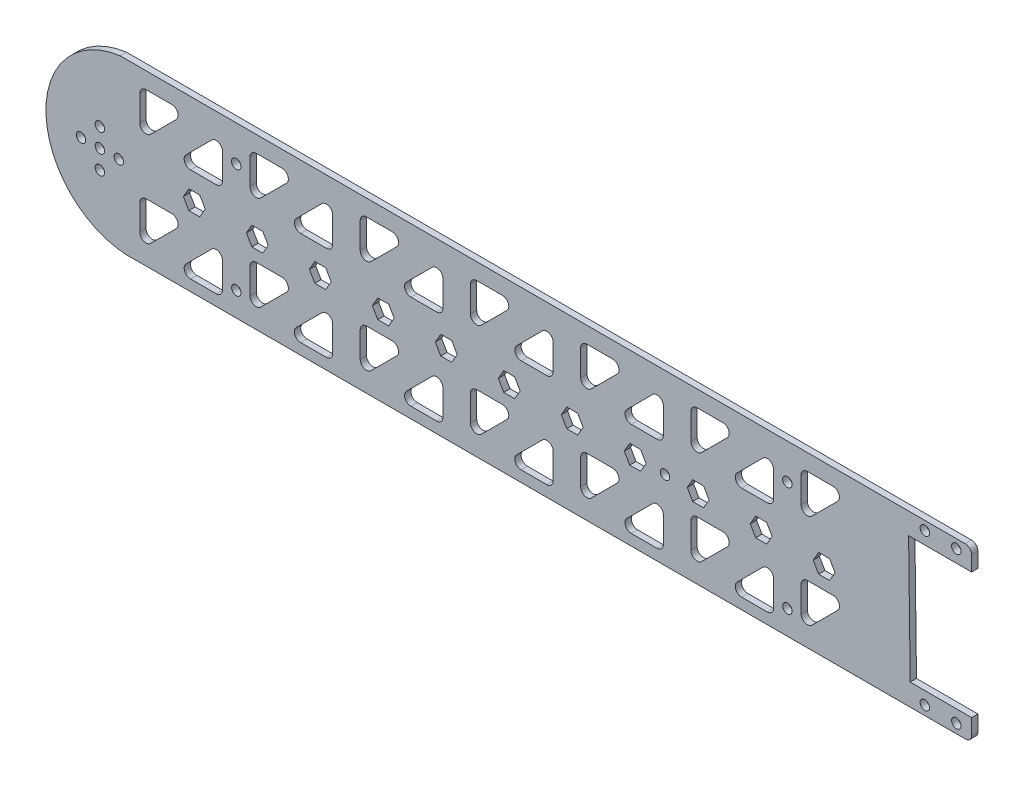
from build123d import *

# Parameters (mm, degrees)
IZIM1_R                     = 1.5
Y_KSEKLIK_EKSTR_ZYON2_DEPTH = 2
IZIM9_R                     = 1.5
KES_EKSTR_ZYON5_DEPTH       = 10
IZIM10_R                    = 1.5
KES_EKSTR_ZYON7_DEPTH       = 10


with BuildPart() as part:
    # Çizim1 → Yükseklik-Ekstrüzyon2 (new body)
    with BuildSketch(Plane.XY):
        with BuildLine():
            ThreePointArc((-123.68208832, 28.6803889), (-147.097650837, -0.85979795), (-118.162671893, -25.019230903))
            Line((-118.162671893, -25.019230903), (122.31562704, -25.019230903))
            Line((122.31562704, -25.019230903), (144.746839173, -25.019230903))
            ThreePointArc((144.746839173, -25.019230903), (146.161052735, -24.433444465), (146.746839173, -23.019230903))
            Line((146.746839173, -23.019230903), (146.746839173, -18.118237576))
            Line((146.746839173, -18.118237576), (127.216282083, -18.118237576))
            Line((127.216282083, -18.118237576), (126.706405407, 21.900803601))
            Line((126.706405407, 21.900803601), (146.706405407, 21.900803601))
            Line((146.706405407, 21.900803601), (146.706405407, 26.6803889))
            ThreePointArc((146.706405407, 26.6803889), (146.120618969, 28.094602463), (144.706405407, 28.6803889))
            Line((144.706405407, 28.6803889), (-123.68208832, 28.6803889))
        make_face()
        with BuildLine():
            Line((-117.432950192, -16.684982837), (-117.432950192, -8.513409962))
            ThreePointArc((-117.432950192, -8.513409962), (-116.847163754, -7.099196399), (-115.432950192, -6.513409962))
            Line((-115.432950192, -6.513409962), (-107.261377316, -6.513409962))
            ThreePointArc((-107.261377316, -6.513409962), (-105.413618251, -7.748043097), (-105.847163754, -9.927623524))
            Line((-105.847163754, -9.927623524), (-114.018736629, -18.099196399))
            ThreePointArc((-114.018736629, -18.099196399), (-116.198317056, -18.532741902), (-117.432950192, -16.684982837))
        make_face(mode=Mode.SUBTRACT)
        with BuildLine():
            Line((-102.756511954, -18.099196399), (-94.584939079, -9.927623524))
            ThreePointArc((-94.584939079, -9.927623524), (-92.405358652, -9.494078021), (-91.170725517, -11.341837086))
            Line((-91.170725517, -11.341837086), (-91.170725517, -19.513409962))
            ThreePointArc((-91.170725517, -19.513409962), (-91.756511954, -20.927623524), (-93.170725517, -21.513409962))
            Line((-93.170725517, -21.513409962), (-101.342298392, -21.513409962))
            ThreePointArc((-101.342298392, -21.513409962), (-103.190057457, -20.278776826), (-102.756511954, -18.099196399))
        make_face(mode=Mode.SUBTRACT)
        with BuildLine():
            Line((-82.432950192, -16.684982837), (-82.432950192, -8.513409962))
            ThreePointArc((-82.432950192, -8.513409962), (-81.847163754, -7.099196399), (-80.432950192, -6.513409962))
            Line((-80.432950192, -6.513409962), (-72.261377316, -6.513409962))
            ThreePointArc((-72.261377316, -6.513409962), (-70.413618251, -7.748043097), (-70.847163754, -9.927623524))
            Line((-70.847163754, -9.927623524), (-79.018736629, -18.099196399))
            ThreePointArc((-79.018736629, -18.099196399), (-81.198317056, -18.532741902), (-82.432950192, -16.684982837))
        make_face(mode=Mode.SUBTRACT)
        with BuildLine():
            Line((-67.756511954, -18.099196399), (-59.584939079, -9.927623524))
            ThreePointArc((-59.584939079, -9.927623524), (-57.405358652, -9.494078021), (-56.170725517, -11.341837086))
            Line((-56.170725517, -11.341837086), (-56.170725517, -19.513409962))
            ThreePointArc((-56.170725517, -19.513409962), (-56.756511954, -20.927623524), (-58.170725517, -21.513409962))
            Line((-58.170725517, -21.513409962), (-66.342298392, -21.513409962))
            ThreePointArc((-66.342298392, -21.513409962), (-68.190057457, -20.278776826), (-67.756511954, -18.099196399))
        make_face(mode=Mode.SUBTRACT)
        with BuildLine():
            Line((-47.432950192, -16.684982837), (-47.432950192, -8.513409962))
            ThreePointArc((-47.432950192, -8.513409962), (-46.847163754, -7.099196399), (-45.432950192, -6.513409962))
            Line((-45.432950192, -6.513409962), (-37.261377316, -6.513409962))
            ThreePointArc((-37.261377316, -6.513409962), (-35.413618251, -7.748043097), (-35.847163754, -9.927623524))
            Line((-35.847163754, -9.927623524), (-44.018736629, -18.099196399))
            ThreePointArc((-44.018736629, -18.099196399), (-46.198317056, -18.532741902), (-47.432950192, -16.684982837))
        make_face(mode=Mode.SUBTRACT)
        with BuildLine():
            Line((-32.756511954, -18.099196399), (-24.584939079, -9.927623524))
            ThreePointArc((-24.584939079, -9.927623524), (-22.405358652, -9.494078021), (-21.170725517, -11.341837086))
            Line((-21.170725517, -11.341837086), (-21.170725517, -19.513409962))
            ThreePointArc((-21.170725517, -19.513409962), (-21.756511954, -20.927623524), (-23.170725517, -21.513409962))
            Line((-23.170725517, -21.513409962), (-31.342298392, -21.513409962))
            ThreePointArc((-31.342298392, -21.513409962), (-33.190057457, -20.278776826), (-32.756511954, -18.099196399))
        make_face(mode=Mode.SUBTRACT)
        with BuildLine():
            Line((-12.432950192, -16.684982837), (-12.432950192, -8.513409962))
            ThreePointArc((-12.432950192, -8.513409962), (-11.847163754, -7.099196399), (-10.432950192, -6.513409962))
            Line((-10.432950192, -6.513409962), (-2.261377316, -6.513409962))
            ThreePointArc((-2.261377316, -6.513409962), (-0.413618251, -7.748043097), (-0.847163754, -9.927623524))
            Line((-0.847163754, -9.927623524), (-9.018736629, -18.099196399))
            ThreePointArc((-9.018736629, -18.099196399), (-11.198317056, -18.532741902), (-12.432950192, -16.684982837))
        make_face(mode=Mode.SUBTRACT)
        Polygon((-96.652716692, 0.01885212), (-98.388672632, -2.978889859), (-101.85277131, -2.974378905), (-103.580914048, 0.027874028), (-101.844958108, 3.025616007), (-98.38085943, 3.021105053), align=None, mode=Mode.SUBTRACT)
        Polygon((-76.652716692, 0.01885212), (-78.388672632, -2.978889859), (-81.85277131, -2.974378905), (-83.580914048, 0.027874028), (-81.844958108, 3.025616007), (-78.38085943, 3.021105053), align=None, mode=Mode.SUBTRACT)
        Polygon((-56.652716692, 0.01885212), (-58.388672632, -2.978889859), (-61.85277131, -2.974378905), (-63.580914048, 0.027874028), (-61.844958108, 3.025616007), (-58.38085943, 3.021105053), align=None, mode=Mode.SUBTRACT)
        Polygon((-36.652716692, 0.01885212), (-38.388672632, -2.978889859), (-41.85277131, -2.974378905), (-43.580914048, 0.027874028), (-41.844958108, 3.025616007), (-38.38085943, 3.021105053), align=None, mode=Mode.SUBTRACT)
        Polygon((-16.652716692, 0.01885212), (-18.388672632, -2.978889859), (-21.85277131, -2.974378905), (-23.580914048, 0.027874028), (-21.844958108, 3.025616007), (-18.38085943, 3.021105053), align=None, mode=Mode.SUBTRACT)
        Polygon((3.347283308, 0.01885212), (1.611327368, -2.978889859), (-1.85277131, -2.974378905), (-3.580914048, 0.027874028), (-1.844958108, 3.025616007), (1.61914057, 3.021105053), align=None, mode=Mode.SUBTRACT)
        with BuildLine():
            Line((2.243488046, -18.099196399), (10.415060921, -9.927623524))
            ThreePointArc((10.415060921, -9.927623524), (12.594641348, -9.494078021), (13.829274483, -11.341837086))
            Line((13.829274483, -11.341837086), (13.829274483, -19.513409962))
            ThreePointArc((13.829274483, -19.513409962), (13.243488046, -20.927623524), (11.829274483, -21.513409962))
            Line((11.829274483, -21.513409962), (3.657701608, -21.513409962))
            ThreePointArc((3.657701608, -21.513409962), (1.809942543, -20.278776826), (2.243488046, -18.099196399))
        make_face(mode=Mode.SUBTRACT)
        with BuildLine():
            Line((22.567049808, -16.684982837), (22.567049808, -8.513409962))
            ThreePointArc((22.567049808, -8.513409962), (23.152836246, -7.099196399), (24.567049808, -6.513409962))
            Line((24.567049808, -6.513409962), (32.738622684, -6.513409962))
            ThreePointArc((32.738622684, -6.513409962), (34.586381749, -7.748043097), (34.152836246, -9.927623524))
            Line((34.152836246, -9.927623524), (25.981263371, -18.099196399))
            ThreePointArc((25.981263371, -18.099196399), (23.801682944, -18.532741902), (22.567049808, -16.684982837))
        make_face(mode=Mode.SUBTRACT)
        with BuildLine():
            Line((37.243488046, -18.099196399), (45.415060921, -9.927623524))
            ThreePointArc((45.415060921, -9.927623524), (47.594641348, -9.494078021), (48.829274483, -11.341837086))
            Line((48.829274483, -11.341837086), (48.829274483, -19.513409962))
            ThreePointArc((48.829274483, -19.513409962), (48.243488046, -20.927623524), (46.829274483, -21.513409962))
            Line((46.829274483, -21.513409962), (38.657701608, -21.513409962))
            ThreePointArc((38.657701608, -21.513409962), (36.809942543, -20.278776826), (37.243488046, -18.099196399))
        make_face(mode=Mode.SUBTRACT)
        with BuildLine():
            Line((57.567049808, -16.684982837), (57.567049808, -8.513409962))
            ThreePointArc((57.567049808, -8.513409962), (58.152836246, -7.099196399), (59.567049808, -6.513409962))
            Line((59.567049808, -6.513409962), (67.738622684, -6.513409962))
            ThreePointArc((67.738622684, -6.513409962), (69.586381749, -7.748043097), (69.152836246, -9.927623524))
            Line((69.152836246, -9.927623524), (60.981263371, -18.099196399))
            ThreePointArc((60.981263371, -18.099196399), (58.801682944, -18.532741902), (57.567049808, -16.684982837))
        make_face(mode=Mode.SUBTRACT)
        with Locations((131.859799091, -22.099196399)):
            Circle(IZIM1_R, mode=Mode.SUBTRACT)
        with Locations((141.859799091, -22.099196399)):
            Circle(IZIM1_R, mode=Mode.SUBTRACT)
        with BuildLine():
            Line((72.243488046, -18.099196399), (80.415060921, -9.927623524))
            ThreePointArc((80.415060921, -9.927623524), (82.594641348, -9.494078021), (83.829274483, -11.341837086))
            Line((83.829274483, -11.341837086), (83.829274483, -19.513409962))
            ThreePointArc((83.829274483, -19.513409962), (83.243488046, -20.927623524), (81.829274483, -21.513409962))
            Line((81.829274483, -21.513409962), (73.657701608, -21.513409962))
            ThreePointArc((73.657701608, -21.513409962), (71.809942543, -20.278776826), (72.243488046, -18.099196399))
        make_face(mode=Mode.SUBTRACT)
        with BuildLine():
            Line((92.567049808, -16.684982837), (92.567049808, -8.513409962))
            ThreePointArc((92.567049808, -8.513409962), (93.152836246, -7.099196399), (94.567049808, -6.513409962))
            Line((94.567049808, -6.513409962), (102.738622684, -6.513409962))
            ThreePointArc((102.738622684, -6.513409962), (104.586381749, -7.748043097), (104.152836246, -9.927623524))
            Line((104.152836246, -9.927623524), (95.981263371, -18.099196399))
            ThreePointArc((95.981263371, -18.099196399), (93.801682944, -18.532741902), (92.567049808, -16.684982837))
        make_face(mode=Mode.SUBTRACT)
        Polygon((23.347283308, 0.01885212), (21.611327368, -2.978889859), (18.14722869, -2.974378905), (16.419085952, 0.027874028), (18.155041892, 3.025616007), (21.61914057, 3.021105053), align=None, mode=Mode.SUBTRACT)
        Polygon((43.347283308, 0.01885212), (41.611327368, -2.978889859), (38.14722869, -2.974378905), (36.419085952, 0.027874028), (38.155041892, 3.025616007), (41.61914057, 3.021105053), align=None, mode=Mode.SUBTRACT)
        Polygon((63.347283308, 0.01885212), (61.611327368, -2.978889859), (58.14722869, -2.974378905), (56.419085952, 0.027874028), (58.155041892, 3.025616007), (61.61914057, 3.021105053), align=None, mode=Mode.SUBTRACT)
        Polygon((83.347283308, 0.01885212), (81.611327368, -2.978889859), (78.14722869, -2.974378905), (76.419085952, 0.027874028), (78.155041892, 3.025616007), (81.61914057, 3.021105053), align=None, mode=Mode.SUBTRACT)
        Polygon((103.347283308, 0.01885212), (101.611327368, -2.978889859), (98.14722869, -2.974378905), (96.419085952, 0.027874028), (98.155041892, 3.025616007), (101.61914057, 3.021105053), align=None, mode=Mode.SUBTRACT)
        with BuildLine():
            Line((-102.756511954, 11.900803601), (-94.584939079, 20.072376476))
            ThreePointArc((-94.584939079, 20.072376476), (-92.405358652, 20.505921979), (-91.170725517, 18.658162914))
            Line((-91.170725517, 18.658162914), (-91.170725517, 10.486590038))
            ThreePointArc((-91.170725517, 10.486590038), (-91.756511954, 9.072376476), (-93.170725517, 8.486590038))
            Line((-93.170725517, 8.486590038), (-101.342298392, 8.486590038))
            ThreePointArc((-101.342298392, 8.486590038), (-103.190057457, 9.721223174), (-102.756511954, 11.900803601))
        make_face(mode=Mode.SUBTRACT)
        with BuildLine():
            Line((-67.756511954, 11.900803601), (-59.584939079, 20.072376476))
            ThreePointArc((-59.584939079, 20.072376476), (-57.405358652, 20.505921979), (-56.170725517, 18.658162914))
            Line((-56.170725517, 18.658162914), (-56.170725517, 10.486590038))
            ThreePointArc((-56.170725517, 10.486590038), (-56.756511954, 9.072376476), (-58.170725517, 8.486590038))
            Line((-58.170725517, 8.486590038), (-66.342298392, 8.486590038))
            ThreePointArc((-66.342298392, 8.486590038), (-68.190057457, 9.721223174), (-67.756511954, 11.900803601))
        make_face(mode=Mode.SUBTRACT)
        with BuildLine():
            Line((-32.756511954, 11.900803601), (-24.584939079, 20.072376476))
            ThreePointArc((-24.584939079, 20.072376476), (-22.405358652, 20.505921979), (-21.170725517, 18.658162914))
            Line((-21.170725517, 18.658162914), (-21.170725517, 10.486590038))
            ThreePointArc((-21.170725517, 10.486590038), (-21.756511954, 9.072376476), (-23.170725517, 8.486590038))
            Line((-23.170725517, 8.486590038), (-31.342298392, 8.486590038))
            ThreePointArc((-31.342298392, 8.486590038), (-33.190057457, 9.721223174), (-32.756511954, 11.900803601))
        make_face(mode=Mode.SUBTRACT)
        with BuildLine():
            Line((-117.432950192, 13.315017163), (-117.432950192, 21.486590038))
            ThreePointArc((-117.432950192, 21.486590038), (-116.847163754, 22.900803601), (-115.432950192, 23.486590038))
            Line((-115.432950192, 23.486590038), (-107.261377316, 23.486590038))
            ThreePointArc((-107.261377316, 23.486590038), (-105.413618251, 22.251956903), (-105.847163754, 20.072376476))
            Line((-105.847163754, 20.072376476), (-114.018736629, 11.900803601))
            ThreePointArc((-114.018736629, 11.900803601), (-116.198317056, 11.467258098), (-117.432950192, 13.315017163))
        make_face(mode=Mode.SUBTRACT)
        with BuildLine():
            Line((-82.432950192, 13.315017163), (-82.432950192, 21.486590038))
            ThreePointArc((-82.432950192, 21.486590038), (-81.847163754, 22.900803601), (-80.432950192, 23.486590038))
            Line((-80.432950192, 23.486590038), (-72.261377316, 23.486590038))
            ThreePointArc((-72.261377316, 23.486590038), (-70.413618251, 22.251956903), (-70.847163754, 20.072376476))
            Line((-70.847163754, 20.072376476), (-79.018736629, 11.900803601))
            ThreePointArc((-79.018736629, 11.900803601), (-81.198317056, 11.467258098), (-82.432950192, 13.315017163))
        make_face(mode=Mode.SUBTRACT)
        with BuildLine():
            Line((-47.432950192, 13.315017163), (-47.432950192, 21.486590038))
            ThreePointArc((-47.432950192, 21.486590038), (-46.847163754, 22.900803601), (-45.432950192, 23.486590038))
            Line((-45.432950192, 23.486590038), (-37.261377316, 23.486590038))
            ThreePointArc((-37.261377316, 23.486590038), (-35.413618251, 22.251956903), (-35.847163754, 20.072376476))
            Line((-35.847163754, 20.072376476), (-44.018736629, 11.900803601))
            ThreePointArc((-44.018736629, 11.900803601), (-46.198317056, 11.467258098), (-47.432950192, 13.315017163))
        make_face(mode=Mode.SUBTRACT)
        with BuildLine():
            Line((-12.432950192, 13.315017163), (-12.432950192, 21.486590038))
            ThreePointArc((-12.432950192, 21.486590038), (-11.847163754, 22.900803601), (-10.432950192, 23.486590038))
            Line((-10.432950192, 23.486590038), (-2.261377316, 23.486590038))
            ThreePointArc((-2.261377316, 23.486590038), (-0.413618251, 22.251956903), (-0.847163754, 20.072376476))
            Line((-0.847163754, 20.072376476), (-9.018736629, 11.900803601))
            ThreePointArc((-9.018736629, 11.900803601), (-11.198317056, 11.467258098), (-12.432950192, 13.315017163))
        make_face(mode=Mode.SUBTRACT)
        with BuildLine():
            Line((2.243488046, 11.900803601), (10.415060921, 20.072376476))
            ThreePointArc((10.415060921, 20.072376476), (12.594641348, 20.505921979), (13.829274483, 18.658162914))
            Line((13.829274483, 18.658162914), (13.829274483, 10.486590038))
            ThreePointArc((13.829274483, 10.486590038), (13.243488046, 9.072376476), (11.829274483, 8.486590038))
            Line((11.829274483, 8.486590038), (3.657701608, 8.486590038))
            ThreePointArc((3.657701608, 8.486590038), (1.809942543, 9.721223174), (2.243488046, 11.900803601))
        make_face(mode=Mode.SUBTRACT)
        with BuildLine():
            Line((37.243488046, 11.900803601), (45.415060921, 20.072376476))
            ThreePointArc((45.415060921, 20.072376476), (47.594641348, 20.505921979), (48.829274483, 18.658162914))
            Line((48.829274483, 18.658162914), (48.829274483, 10.486590038))
            ThreePointArc((48.829274483, 10.486590038), (48.243488046, 9.072376476), (46.829274483, 8.486590038))
            Line((46.829274483, 8.486590038), (38.657701608, 8.486590038))
            ThreePointArc((38.657701608, 8.486590038), (36.809942543, 9.721223174), (37.243488046, 11.900803601))
        make_face(mode=Mode.SUBTRACT)
        with BuildLine():
            Line((72.243488046, 11.900803601), (80.415060921, 20.072376476))
            ThreePointArc((80.415060921, 20.072376476), (82.594641348, 20.505921979), (83.829274483, 18.658162914))
            Line((83.829274483, 18.658162914), (83.829274483, 10.486590038))
            ThreePointArc((83.829274483, 10.486590038), (83.243488046, 9.072376476), (81.829274483, 8.486590038))
            Line((81.829274483, 8.486590038), (73.657701608, 8.486590038))
            ThreePointArc((73.657701608, 8.486590038), (71.809942543, 9.721223174), (72.243488046, 11.900803601))
        make_face(mode=Mode.SUBTRACT)
        with BuildLine():
            Line((22.567049808, 13.315017163), (22.567049808, 21.486590038))
            ThreePointArc((22.567049808, 21.486590038), (23.152836246, 22.900803601), (24.567049808, 23.486590038))
            Line((24.567049808, 23.486590038), (32.738622684, 23.486590038))
            ThreePointArc((32.738622684, 23.486590038), (34.586381749, 22.251956903), (34.152836246, 20.072376476))
            Line((34.152836246, 20.072376476), (25.981263371, 11.900803601))
            ThreePointArc((25.981263371, 11.900803601), (23.801682944, 11.467258098), (22.567049808, 13.315017163))
        make_face(mode=Mode.SUBTRACT)
        with BuildLine():
            Line((57.567049808, 13.315017163), (57.567049808, 21.486590038))
            ThreePointArc((57.567049808, 21.486590038), (58.152836246, 22.900803601), (59.567049808, 23.486590038))
            Line((59.567049808, 23.486590038), (67.738622684, 23.486590038))
            ThreePointArc((67.738622684, 23.486590038), (69.586381749, 22.251956903), (69.152836246, 20.072376476))
            Line((69.152836246, 20.072376476), (60.981263371, 11.900803601))
            ThreePointArc((60.981263371, 11.900803601), (58.801682944, 11.467258098), (57.567049808, 13.315017163))
        make_face(mode=Mode.SUBTRACT)
        with BuildLine():
            Line((92.567049808, 13.315017163), (92.567049808, 21.486590038))
            ThreePointArc((92.567049808, 21.486590038), (93.152836246, 22.900803601), (94.567049808, 23.486590038))
            Line((94.567049808, 23.486590038), (102.738622684, 23.486590038))
            ThreePointArc((102.738622684, 23.486590038), (104.586381749, 22.251956903), (104.152836246, 20.072376476))
            Line((104.152836246, 20.072376476), (95.981263371, 11.900803601))
            ThreePointArc((95.981263371, 11.900803601), (93.801682944, 11.467258098), (92.567049808, 13.315017163))
        make_face(mode=Mode.SUBTRACT)
        with Locations((131.859799091, 25.900803601)):
            Circle(IZIM1_R, mode=Mode.SUBTRACT)
        with Locations((141.859799091, 25.900803601)):
            Circle(IZIM1_R, mode=Mode.SUBTRACT)
        with Locations((-130.106258095, 6.023363074)):
            Circle(IZIM1_R, mode=Mode.SUBTRACT)
        with Locations((-130.106258095, -5.976636926)):
            Circle(IZIM1_R, mode=Mode.SUBTRACT)
        with Locations((-136.106258095, 0.023363074)):
            Circle(IZIM1_R, mode=Mode.SUBTRACT)
        with Locations((-130.106258095, 0.023363074)):
            Circle(IZIM1_R, mode=Mode.SUBTRACT)
        with Locations((-124.106258095, 0.023363074)):
            Circle(IZIM1_R, mode=Mode.SUBTRACT)
    extrude(amount=Y_KSEKLIK_EKSTR_ZYON2_DEPTH)

    # Çizim9 → Kes-Ekstrüzyon5 (cut)
    with BuildSketch(Plane(origin=(0, 0, 0), x_dir=(-1, 0, 0), z_dir=(0, 0, -1))):
        with Locations((-88.198162146, 17.400803601)):
            Circle(IZIM9_R)
        with Locations((-88.222150893, -17.356386837)):
            Circle(IZIM9_R)
        with Locations((86.801837854, 17.400803601)):
            Circle(IZIM9_R)
        with Locations((86.777849107, -17.356386837)):
            Circle(IZIM9_R)
    extrude(amount=-KES_EKSTR_ZYON5_DEPTH, mode=Mode.SUBTRACT)

    # Çizim10 → Kes-Ekstrüzyon7 (cut)
    with BuildSketch(Plane.XY.offset(2)):
        with Locations((49.347283308, 0)):
            Circle(IZIM10_R)
    extrude(amount=-KES_EKSTR_ZYON7_DEPTH, mode=Mode.SUBTRACT)


solid = part.part
